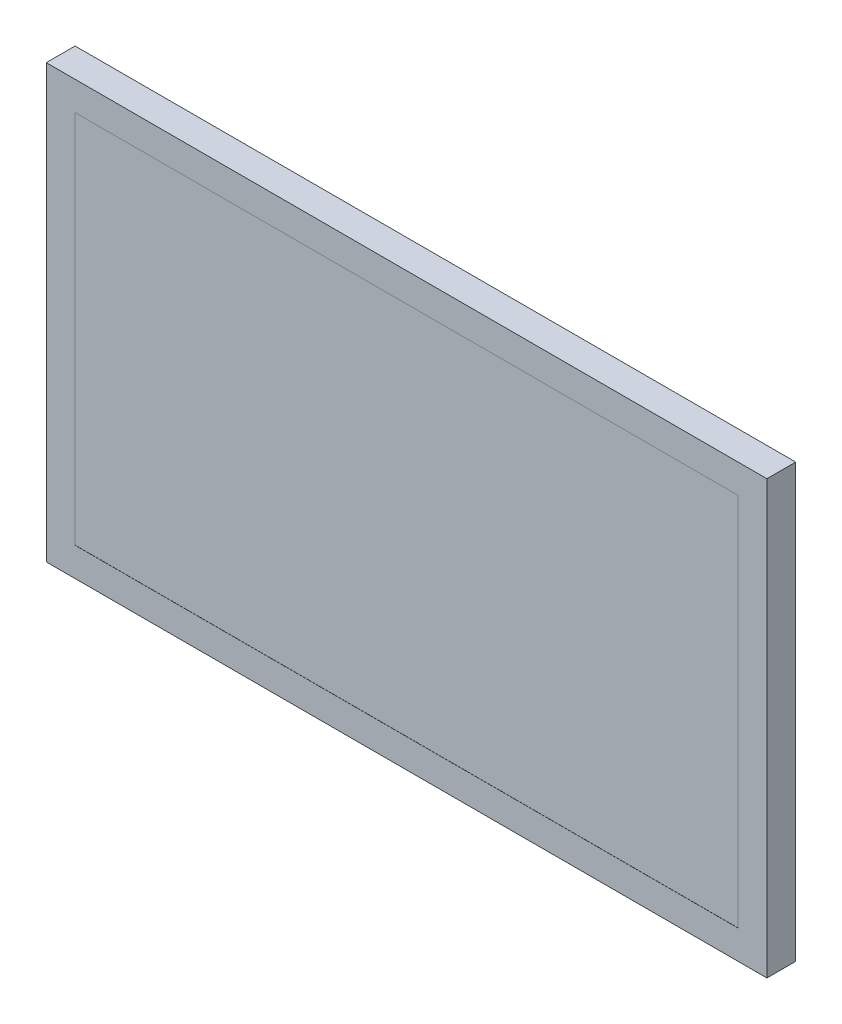
from build123d import *

# Parameters (mm, degrees)
SKETCH1_W           = 500
SKETCH1_H           = 300
BOSS_EXTRUDE1_DEPTH = 20
SKETCH2_W           = 460
SKETCH2_H           = 260
CUT_EXTRUDE1_DEPTH  = 0.1


with BuildPart() as part:
    # Sketch1 → Boss-Extrude1 (new body)
    with BuildSketch(Plane.XY):
        Rectangle(SKETCH1_W, SKETCH1_H)
    extrude(amount=BOSS_EXTRUDE1_DEPTH)

    # Sketch2 → Cut-Extrude1 (cut)
    with BuildSketch(Plane.XY.offset(20)):
        Rectangle(SKETCH2_W, SKETCH2_H)
    extrude(amount=-CUT_EXTRUDE1_DEPTH, mode=Mode.SUBTRACT)


solid = part.part
